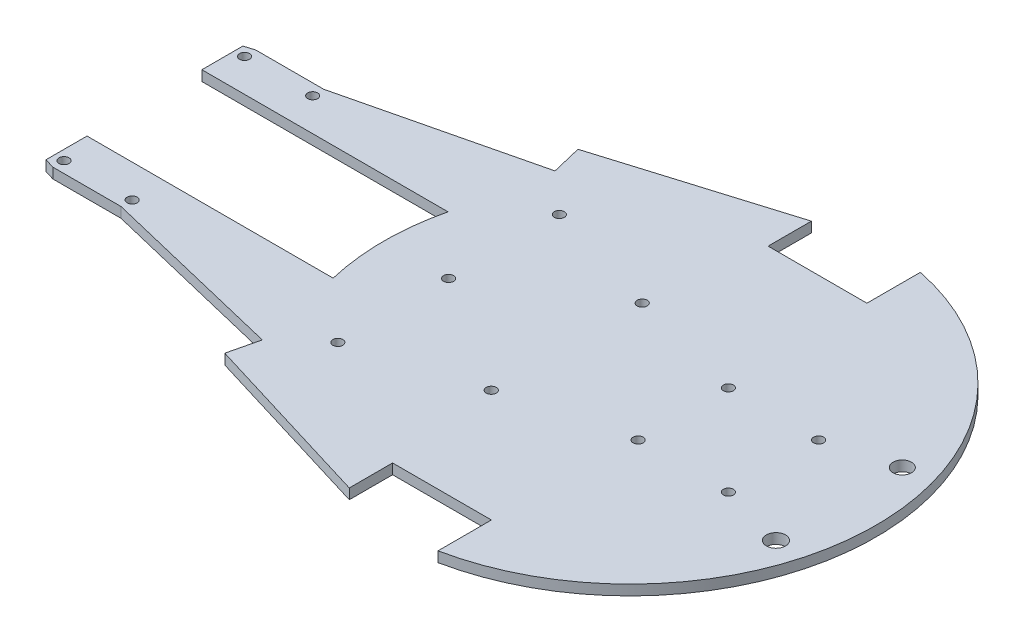
from build123d import *

# Parameters (mm, degrees)
SKETCH1_R           = 1.55
SKETCH1_R_2         = 2.97333552
SKETCH1_R_3         = 2.85410663
BOSS_EXTRUDE1_DEPTH = 3.175
CUT_EXTRUDE1_DEPTH  = 3.175


with BuildPart() as part:
    # Sketch1 → Boss-Extrude1 (new body)
    with BuildSketch(Plane(origin=(0, 0, 0), x_dir=(1, 0, 0), z_dir=(0, 1, 0))):
        with BuildLine():
            Line((-15.352336135, 71.529843551), (-126.166636901, 37.820307959))
            Line((-126.166636901, 37.820307959), (-126.166636901, 31.407196795))
            Line((-126.166636901, 31.407196795), (-147.248636901, 31.407196795))
            Line((-147.248636901, 31.407196795), (-150.296636901, 30.48))
            Line((-150.296636901, 30.48), (-150.296636901, 17.78))
            Line((-150.296636901, 17.78), (-74.096636901, 17.78))
            ThreePointArc((-74.096636901, 17.78), (-76.2, 0), (-74.096636901, -17.78))
            Line((-74.096636901, -17.78), (-150.296636901, -17.78))
            Line((-150.296636901, -17.78), (-150.296636901, -30.48))
            Line((-150.296636901, -30.48), (-147.248636901, -31.407196795))
            Line((-147.248636901, -31.407196795), (-126.166636901, -31.407196795))
            Line((-126.166636901, -31.407196795), (-126.166636901, -37.820307959))
            Line((-126.166636901, -37.820307959), (-15.352336135, -71.529843551))
            Line((-15.352336135, -71.529843551), (-15.352336135, -58.127428782))
            Line((-15.352336135, -58.127428782), (15.24, -58.127428782))
            Line((15.24, -58.127428782), (15.24, -74.66044736))
            ThreePointArc((15.24, -74.66044736), (76.2, 0), (15.24, 74.66044736))
            Line((15.24, 74.66044736), (15.24, 58.127428782))
            Line((15.24, 58.127428782), (-15.352336135, 58.127428782))
            Line((-15.352336135, 58.127428782), (-15.352336135, 71.529843551))
        make_face()
        with Locations((-56.1402016, 0)):
            Circle(SKETCH1_R, mode=Mode.SUBTRACT)
        with Locations((-19.5642016, -23.368)):
            Circle(SKETCH1_R, mode=Mode.SUBTRACT)
        with Locations((64.77, -19.558)):
            Circle(SKETCH1_R_2, mode=Mode.SUBTRACT)
        with Locations((16.51, -13.97)):
            Circle(SKETCH1_R, mode=Mode.SUBTRACT)
        with Locations((44.45, -13.97)):
            Circle(SKETCH1_R, mode=Mode.SUBTRACT)
        with Locations((-147.248636901, 27.94)):
            Circle(SKETCH1_R, mode=Mode.SUBTRACT)
        with Locations((-126.166636901, 27.94)):
            Circle(SKETCH1_R, mode=Mode.SUBTRACT)
        with Locations((-56.1402016, 34.29)):
            Circle(SKETCH1_R, mode=Mode.SUBTRACT)
        with Locations((16.51, 13.97)):
            Circle(SKETCH1_R, mode=Mode.SUBTRACT)
        with Locations((44.45, 13.97)):
            Circle(SKETCH1_R, mode=Mode.SUBTRACT)
        with Locations((64.77, 19.558)):
            Circle(SKETCH1_R_3, mode=Mode.SUBTRACT)
        with Locations((-19.5642016, 23.368)):
            Circle(SKETCH1_R, mode=Mode.SUBTRACT)
        with Locations((-56.1402016, -34.29)):
            Circle(SKETCH1_R, mode=Mode.SUBTRACT)
        with Locations((-126.166636901, -27.94)):
            Circle(SKETCH1_R, mode=Mode.SUBTRACT)
        with Locations((-147.248636901, -27.94)):
            Circle(SKETCH1_R, mode=Mode.SUBTRACT)
    extrude(amount=BOSS_EXTRUDE1_DEPTH)

    # Sketch2 → Cut-Extrude1 (cut)
    with BuildSketch(Plane(origin=(0, 3.175, 0), x_dir=(1, 0, 0), z_dir=(0, 1, 0))):
        Polygon((-126.166636901, 31.407196795), (-68.501735058, 45.311715833), (-70.759486518, 54.675075755), (-126.166636901, 37.820307959), align=None)
        Polygon((-68.501735058, -45.311715833), (-126.166636901, -31.407196795), (-126.166636901, -37.820307959), (-70.759486518, -54.675075755), align=None)
    extrude(amount=-CUT_EXTRUDE1_DEPTH, mode=Mode.SUBTRACT)


solid = part.part
